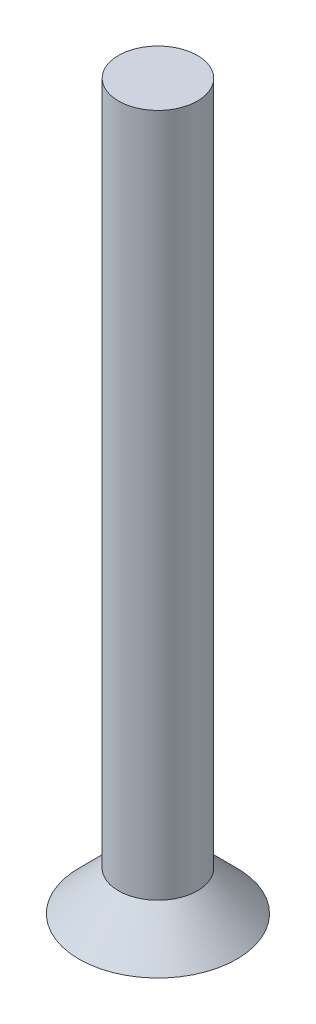
from build123d import *


with BuildPart() as part:
    # Esquisse1 → Révolution1 (revolve)
    with BuildSketch(Plane.XY):
        Polygon((3, 40), (3, -12), (6, -15), (0, -15), (0, 40), align=None)
    revolve(axis=Axis((0, 0, 0), (0, -1, 0)))


solid = part.part
